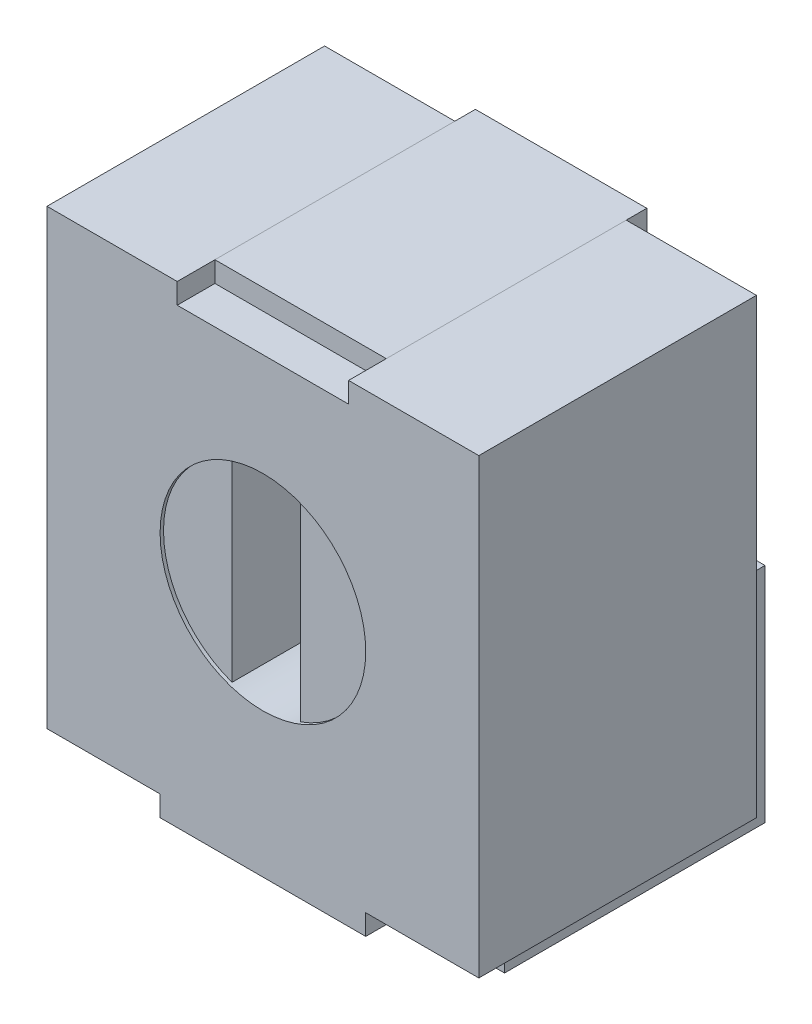
from build123d import *

# Parameters (mm, degrees)
BOSS_EXTRUDE1_DEPTH       = 2.0574
SKETCH2_R                 = 0.762
CUT_EXTRUDE1_DEPTH        = 0.0254
CUT_EXTRUDE2_DEPTH        = 0.508
EXTRUDE_THIN1_DEPTH       = 0.635
EXTRUDE_THIN6_DEPTH       = 0.3302
CHAMFER1_SIZE             = 0.381
CHAMFER1_SIZE2            = 0.544124391
CHAMFER1_OF_MIRROR1_SIZE2 = 0.544124391
CHAMFER1_OF_MIRROR1_SIZE  = 0.381


with BuildPart() as part:
    # Sketch1 → Boss-Extrude1 (new body)
    with BuildSketch(Plane.XY):
        Polygon((0, 0), (0.8382, 0), (0.8382, -0.1524), (2.3622, -0.1524), (2.3622, 0), (3.2004, 0), (3.2004, 3.3528), (2.2352, 3.3528), (2.2352, 3.2004), (0.9652, 3.2004), (0.9652, 3.3528), (0, 3.3528), align=None)
    extrude(amount=BOSS_EXTRUDE1_DEPTH)

    # Sketch2 → Cut-Extrude1 (cut)
    with BuildSketch(Plane.XY.offset(2.0574)):
        with Locations((1.6002, 1.6764)):
            Circle(SKETCH2_R)
    extrude(amount=-CUT_EXTRUDE1_DEPTH, mode=Mode.SUBTRACT)

    # Sketch3 → Cut-Extrude2 (cut)
    with BuildSketch(Plane.XY.offset(2.032)):
        with BuildLine():
            Line((1.3462, 2.39482049), (1.3462, 0.95797951))
            ThreePointArc((1.3462, 0.95797951), (1.6002, 0.9144), (1.8542, 0.95797951))
            Line((1.8542, 0.95797951), (1.8542, 2.39482049))
            ThreePointArc((1.8542, 2.39482049), (1.6002, 2.4384), (1.3462, 2.39482049))
        make_face()
    extrude(amount=-CUT_EXTRUDE2_DEPTH, mode=Mode.SUBTRACT)

    # Sketch8 → Extrude-Thin6 (add, symmetric)
    with BuildSketch(Plane.ZY.offset(-0.4191)):
        Polygon((1.778, 0), (0, 0), (0, 1.4986), (-0.1524, 1.4986), (-0.1524, -0.1524), (1.778, -0.1524), align=None)
    extrude_thin6 = extrude(amount=EXTRUDE_THIN6_DEPTH, both=True)

    # Chamfer1
    chamfer1_edges = [part.edges().sort_by_distance(p)[0] for p in [
        (0.7493, 1.4986, -0.0762),
    ]]
    chamfer1_side = [part.faces().sort_by_distance(p)[0] for p in [
        (0.4191, 1.4986, -0.0762),
    ]]
    chamfer(chamfer1_edges, length=CHAMFER1_SIZE, length2=CHAMFER1_SIZE2, reference=chamfer1_side[0])

    # Mirror1: Extrude-Thin6 across plane
    add(extrude_thin6.mirror(Plane.ZY.offset(-1.6002)))

    # Chamfer1 of Mirror1
    chamfer1_of_mirror1_edges = [part.edges().sort_by_distance(p)[0] for p in [
        (2.4511, 1.4986, -0.0762),
    ]]
    chamfer(chamfer1_of_mirror1_edges, length=CHAMFER1_OF_MIRROR1_SIZE, length2=CHAMFER1_OF_MIRROR1_SIZE2)


with BuildPart() as body_2:
    # Sketch5 → Extrude-Thin1 (new body, symmetric)
    with BuildSketch(Plane.ZY.offset(-1.6002)):
        Polygon((1.778, 3.2004), (0, 3.2004), (0, 1.6764), (-0.1524, 1.6764), (-0.1524, 3.3528), (1.778, 3.3528), align=None)
    extrude(amount=EXTRUDE_THIN1_DEPTH, both=True)


solid = Compound([part.part, body_2.part])
